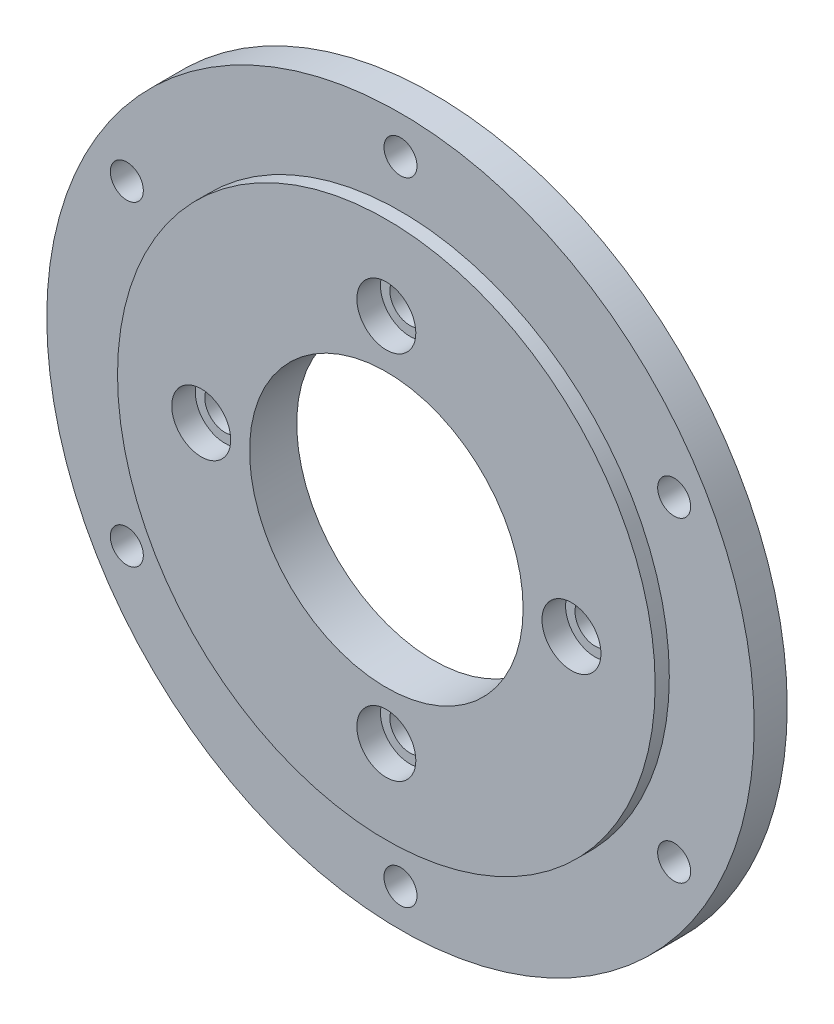
from build123d import *

# Parameters (mm, degrees)
SKETCH1_R           = 75
SKETCH1_R_2         = 29
BOSS_EXTRUDE1_DEPTH = 10
SKETCH2_R           = 84.502985649
SKETCH2_R_2         = 57
CUT_EXTRUDE2_DEPTH  = 3
HOLE1_D             = 8.5
HOLE1_CBORE_D       = 12.5
HOLE1_CBORE_DEPTH   = 5
CIRPATTERN1_COUNT   = 4
HOLE2_D             = 7
CIRPATTERN2_COUNT   = 6


with BuildPart() as part:
    # Sketch1 → Boss-Extrude1 (new body)
    with BuildSketch(Plane.XY):
        Circle(SKETCH1_R)
        Circle(SKETCH1_R_2, mode=Mode.SUBTRACT)
    extrude(amount=BOSS_EXTRUDE1_DEPTH)

    # Sketch2 → Cut-Extrude2 (cut)
    with BuildSketch(Plane.XY.offset(10)):
        Circle(SKETCH2_R)
        Circle(SKETCH2_R_2, mode=Mode.SUBTRACT)
    extrude(amount=-CUT_EXTRUDE2_DEPTH, mode=Mode.SUBTRACT)

    # Hole1 (through all)
    with Locations(Plane(origin=(0, 39.25, 10), x_dir=(1, 0, 0), z_dir=(0, 0, 1))):
        with Locations((0, 0)):
            hole1 = CounterBoreHole(HOLE1_D / 2, HOLE1_CBORE_D / 2, HOLE1_CBORE_DEPTH)

    # CirPattern1: Hole1 ×4 about axis
    cirpattern1_axis = Axis((0, 0, 0), (0, 0, 1))
    for i in range(1, CIRPATTERN1_COUNT):
        add(hole1.rotate(cirpattern1_axis, i * 360 / CIRPATTERN1_COUNT), mode=Mode.SUBTRACT)

    # Hole2 (through all)
    with Locations(Plane.XY.offset(7)):
        with Locations((0, 67)):
            hole2 = Hole(HOLE2_D / 2)

    # CirPattern2: Hole2 ×6 about axis
    cirpattern2_axis = Axis((0, 0, 0), (0, 0, 1))
    for i in range(1, CIRPATTERN2_COUNT):
        add(hole2.rotate(cirpattern2_axis, i * 360 / CIRPATTERN2_COUNT), mode=Mode.SUBTRACT)


solid = part.part
